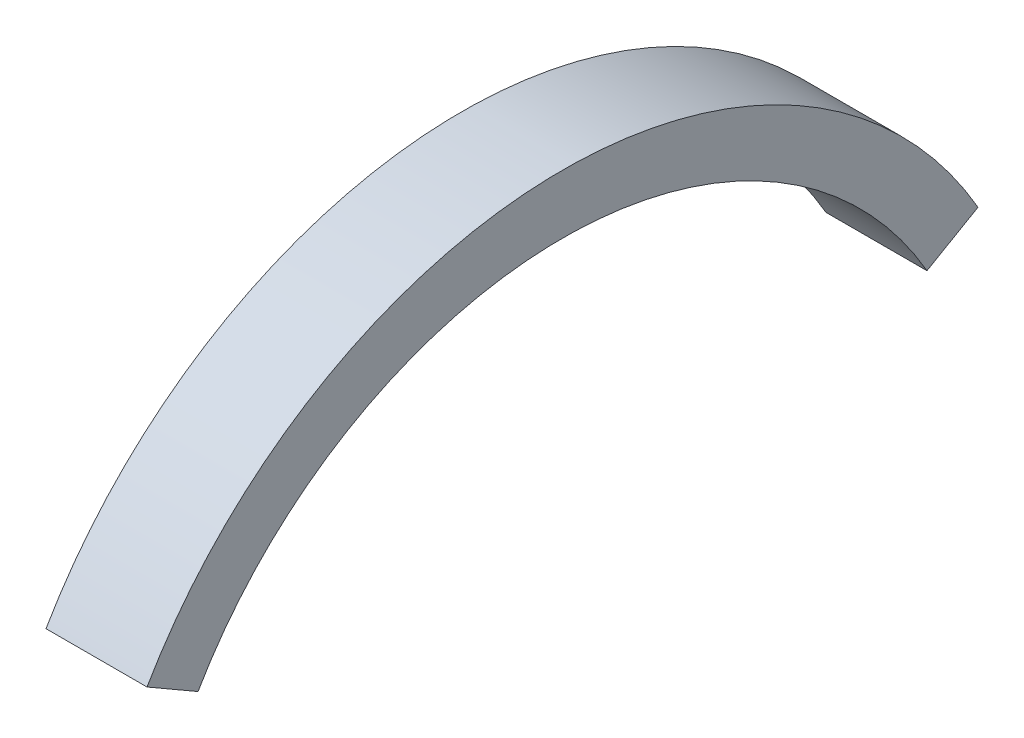
from build123d import *

# Parameters (mm, degrees)
BOSS_EXTRUDE1_DEPTH = 3


with BuildPart() as part:
    # Sketch1 → Boss-Extrude1 (new body, symmetric)
    with BuildSketch(Plane(origin=(0, 0, 0), x_dir=(0, 0, -1), z_dir=(1, 0, 0))):
        with BuildLine():
            Line((-24.681724008, 14.25), (-21.650635095, 12.5))
            ThreePointArc((-21.650635095, 12.5), (0, 25), (21.650635095, 12.5))
            Line((21.650635095, 12.5), (24.681724008, 14.25))
            ThreePointArc((24.681724008, 14.25), (0, 28.5), (-24.681724008, 14.25))
        make_face()
    extrude(amount=BOSS_EXTRUDE1_DEPTH, both=True)


solid = part.part
